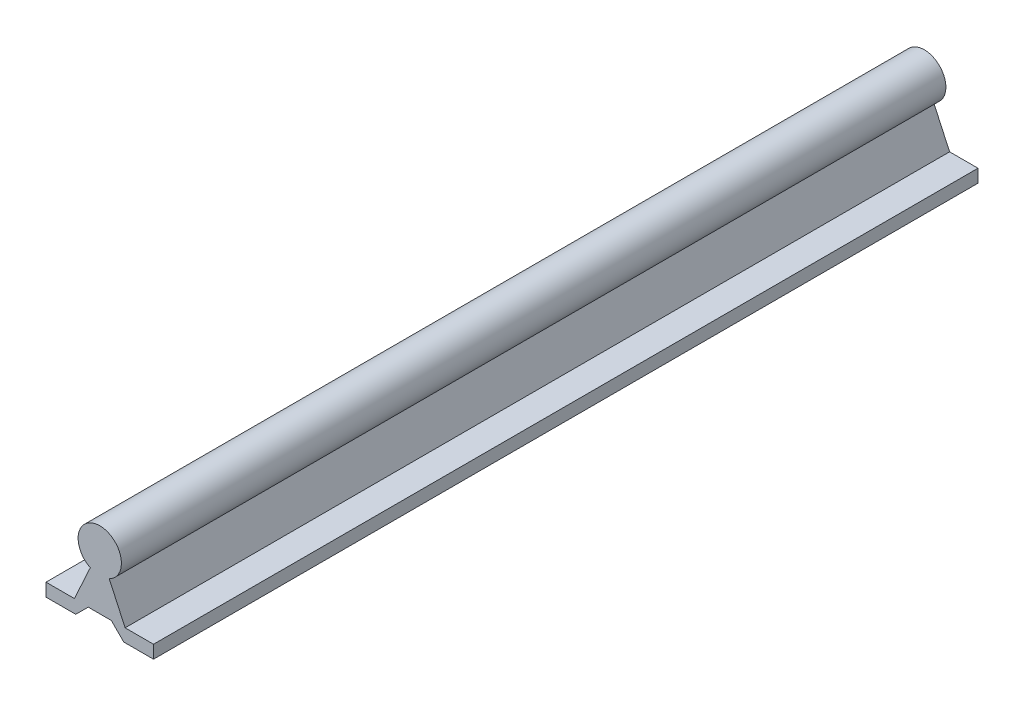
from build123d import *

# Parameters (mm, degrees)
BOSS_EXTRUDE1_DEPTH = 304.8


with BuildPart() as part:
    # Sketch1 → Boss-Extrude1 (new body)
    with BuildSketch(Plane.XY):
        with BuildLine():
            Line((3.5, 17.606252715), (9.375, 4.8))
            Line((9.375, 4.8), (19.875, 4.8))
            Line((19.875, 4.8), (19.875, 0))
            Line((19.875, 0), (8.875, 0))
            Line((8.875, 0), (4.275, 4.6))
            Line((4.275, 4.6), (-4.275, 4.6))
            Line((-4.275, 4.6), (-8.875, 0))
            Line((-8.875, 0), (-19.875, 0))
            Line((-19.875, 0), (-19.875, 4.8))
            Line((-19.875, 4.8), (-9.375, 4.8))
            Line((-9.375, 4.8), (-3.5, 17.606252715))
            ThreePointArc((-3.5, 17.606252715), (0, 32.8), (3.5, 17.606252715))
        make_face()
    extrude(amount=BOSS_EXTRUDE1_DEPTH)


solid = part.part
